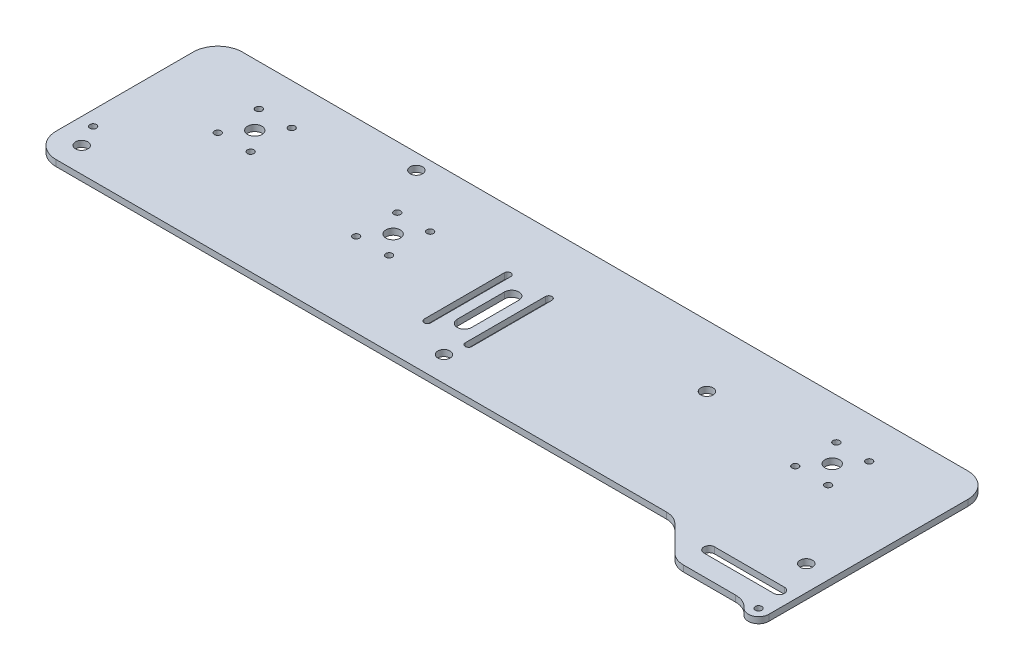
from build123d import *

# Parameters (mm, degrees)
ESBO_O1_R                = 3.5
ESBO_O1_R_2              = 3
ESBO_O1_R_3              = 1.6
RESSALTO_EXTRUS_O1_DEPTH = 3
ESBO_O2_R                = 1.6
RESSALTO_EXTRUS_O2_DEPTH = 3
FILETE2_R                = 10
CORTE_EXTRUS_O1_DEPTH    = 203.904924863


with BuildPart() as part:
    # Esboço1 → Ressalto-extrusão1 (new body)
    with BuildSketch(Plane(origin=(0, 0, 0), x_dir=(1, 0, 0), z_dir=(0, 1, 0))):
        with BuildLine():
            Line((188.965018959, -38.648697641), (188.965018959, 28))
            ThreePointArc((188.965018959, 28), (185.450300333, 36.485281374), (176.965018959, 40))
            Line((176.965018959, 40), (-176.090826953, 40))
            ThreePointArc((-176.090826953, 40), (-184.576108327, 36.485281374), (-188.090826953, 28))
            Line((-188.090826953, 28), (-188.090826953, -38.648697641))
            ThreePointArc((-188.090826953, -38.648697641), (-184.576108327, -47.133979015), (-176.090826953, -50.648697641))
            Line((-176.090826953, -50.648697641), (176.965018959, -50.648697641))
            ThreePointArc((176.965018959, -50.648697641), (185.450300333, -47.133979015), (188.965018959, -38.648697641))
        make_face()
        with Locations(Location((-62.734509176, 0, 0), (0, 0, 90))):
            Circle(ESBO_O1_R, mode=Mode.SUBTRACT)
        with Locations(Location((176.748138959, -38.431817641, 0), (0, 0, 90))):
            Circle(ESBO_O1_R_2, mode=Mode.SUBTRACT)
        with Locations(Location((0.437096003, -38.431817641, 0), (0, 0, 90))):
            Circle(ESBO_O1_R_2, mode=Mode.SUBTRACT)
        with Locations(Location((79.965018959, 10, 0), (0, 0, 90))):
            Circle(ESBO_O1_R_2, mode=Mode.SUBTRACT)
        with Locations(Location((-140.090826953, 10, 0), (0, 0, 90))):
            Circle(ESBO_O1_R, mode=Mode.SUBTRACT)
        with Locations(Location((-148.090826953, 0, 0), (0, 0, 270))):
            Circle(ESBO_O1_R_3, mode=Mode.SUBTRACT)
        with Locations(Location((-132.090826953, 0, 0), (0, 0, 270))):
            Circle(ESBO_O1_R_3, mode=Mode.SUBTRACT)
        with Locations(Location((-132.090826953, 20, 0), (0, 0, 270))):
            Circle(ESBO_O1_R_3, mode=Mode.SUBTRACT)
        with Locations(Location((-148.090826953, 20, 0), (0, 0, 270))):
            Circle(ESBO_O1_R_3, mode=Mode.SUBTRACT)
        with Locations(Location((-70.734509176, -10, 0), (0, 0, 270))):
            Circle(ESBO_O1_R_3, mode=Mode.SUBTRACT)
        with Locations(Location((-70.734509176, 10, 0), (0, 0, 270))):
            Circle(ESBO_O1_R_3, mode=Mode.SUBTRACT)
        with Locations(Location((-54.734509176, 10, 0), (0, 0, 270))):
            Circle(ESBO_O1_R_3, mode=Mode.SUBTRACT)
        with Locations(Location((-54.734509176, -10, 0), (0, 0, 270))):
            Circle(ESBO_O1_R_3, mode=Mode.SUBTRACT)
        with Locations(Location((-83.930342624, 32.5, 0), (0, 0, 90))):
            Circle(ESBO_O1_R_2, mode=Mode.SUBTRACT)
        with Locations(Location((-175.873946953, -38.431817641, 0), (0, 0, 90))):
            Circle(ESBO_O1_R_2, mode=Mode.SUBTRACT)
        with Locations(Location((140.965018959, 10, 0), (0, 0, 90))):
            Circle(ESBO_O1_R, mode=Mode.SUBTRACT)
        with Locations(Location((148.965018959, 0, 0), (0, 0, 90))):
            Circle(ESBO_O1_R_3, mode=Mode.SUBTRACT)
        with Locations(Location((148.965018959, 20, 0), (0, 0, 90))):
            Circle(ESBO_O1_R_3, mode=Mode.SUBTRACT)
        with Locations(Location((132.965018959, 0, 0), (0, 0, 90))):
            Circle(ESBO_O1_R_3, mode=Mode.SUBTRACT)
        with Locations(Location((132.965018959, 20, 0), (0, 0, 90))):
            Circle(ESBO_O1_R_3, mode=Mode.SUBTRACT)
        with Locations(Location((-181.090826953, -27.648697641, 0), (0, 0, 270))):
            Circle(ESBO_O1_R_3, mode=Mode.SUBTRACT)
    extrude(amount=-RESSALTO_EXTRUS_O1_DEPTH)

    # Esboço2 → Ressalto-extrusão2 (add)
    with BuildSketch(Plane.XZ.offset(3)):
        with BuildLine():
            Line((125.022883335, 50.648697641), (176.965018959, 50.648697641))
            ThreePointArc((176.965018959, 50.648697641), (185.450300333, 47.133979015), (188.965018959, 38.648697641))
            Line((188.965018959, 38.648697641), (188.965018959, 68.848697641))
            ThreePointArc((188.965018959, 68.848697641), (183.965018959, 73.848697641), (178.965018959, 68.848697641))
            Line((178.965018959, 68.848697641), (143.222883335, 68.848697641))
            Line((143.222883335, 68.848697641), (125.022883335, 50.648697641))
        make_face()
        with BuildLine():
            Line((147.365018959, 58.848697641), (181.365018959, 58.848697641))
            ThreePointArc((181.365018959, 58.848697641), (183.965018959, 56.248697641), (181.365018959, 53.648697641))
            Line((181.365018959, 53.648697641), (147.365018959, 53.648697641))
            ThreePointArc((147.365018959, 53.648697641), (144.765018959, 56.248697641), (147.365018959, 58.848697641))
        make_face(mode=Mode.SUBTRACT)
        with Locations(Location((183.965018959, 68.848697641, 0), (0, 0, 270))):
            Circle(ESBO_O2_R, mode=Mode.SUBTRACT)
    extrude(amount=-RESSALTO_EXTRUS_O2_DEPTH)

    # Filete2
    filete2_edges = [part.edges().sort_by_distance(p)[0] for p in [
        (125.022883335, -1.5, 50.648697641),
        (143.222883335, -1.5, 68.848697641),
        (178.965018959, -1.5, 68.848697641),
    ]]
    fillet(filete2_edges, radius=FILETE2_R)

    # Esboço3 → Corte-extrusão1 (cut, through all)
    with BuildSketch(Plane(origin=(0, 0, 0), x_dir=(1, 0, 0), z_dir=(0, 1, 0))):
        with BuildLine():
            Line((-4.234509176, 2.700055346), (-4.234509176, -20.299944654))
            ThreePointArc((-4.234509176, -20.299944654), (-7.734509176, -23.799944654), (-11.234509176, -20.299944654))
            Line((-11.234509176, -20.299944654), (-11.234509176, 2.700055346))
            ThreePointArc((-11.234509176, 2.700055346), (-7.734509176, 6.200055346), (-4.234509176, 2.700055346))
        make_face()
        with BuildLine():
            Line((3.865490824, 10.700055346), (3.865490824, -12.299944654))
            ThreePointArc((3.865490824, -12.299944654), (2.265490824, -13.899944654), (0.665490824, -12.299944654))
            Line((0.665490824, -12.299944654), (0.665490824, 10.700055346))
            ThreePointArc((0.665490824, 10.700055346), (2.265490824, 12.300055346), (3.865490824, 10.700055346))
        make_face()
        with BuildLine():
            Line((3.865490824, -5.299944654), (3.865490824, -28.299944654))
            ThreePointArc((3.865490824, -28.299944654), (2.265490824, -29.899944654), (0.665490824, -28.299944654))
            Line((0.665490824, -28.299944654), (0.665490824, -5.299944654))
            ThreePointArc((0.665490824, -5.299944654), (2.265490824, -3.699944654), (3.865490824, -5.299944654))
        make_face()
        with BuildLine():
            Line((-19.334509176, 10.700055346), (-19.334509176, -12.299944654))
            ThreePointArc((-19.334509176, -12.299944654), (-17.734509176, -13.899944654), (-16.134509176, -12.299944654))
            Line((-16.134509176, -12.299944654), (-16.134509176, 10.700055346))
            ThreePointArc((-16.134509176, 10.700055346), (-17.734509176, 12.300055346), (-19.334509176, 10.700055346))
        make_face()
        with BuildLine():
            Line((-19.334509176, -5.299944654), (-19.334509176, -28.299944654))
            ThreePointArc((-19.334509176, -28.299944654), (-17.734509176, -29.899944654), (-16.134509176, -28.299944654))
            Line((-16.134509176, -28.299944654), (-16.134509176, -5.299944654))
            ThreePointArc((-16.134509176, -5.299944654), (-17.734509176, -3.699944654), (-19.334509176, -5.299944654))
        make_face()
    extrude(amount=-CORTE_EXTRUS_O1_DEPTH, mode=Mode.SUBTRACT)


solid = part.part
